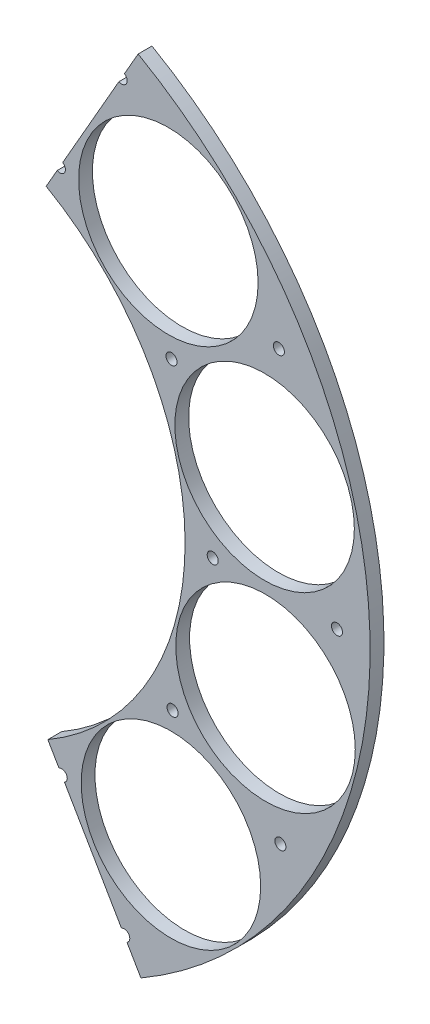
from build123d import *

# Parameters (mm, degrees)
ESQUISSE1_R             = 32.5
BOSS_EXTRU_2_DEPTH      = 5
ESQUISSE2_R             = 2
ENL_V_MAT_EXTRU_1_DEPTH = 5
ENL_V_MAT_EXTRU_2_DEPTH = 10


with BuildPart() as part:
    # Esquisse1 → Boss.-Extru.2 (new body)
    with BuildSketch(Plane.XY):
        with BuildLine():
            Line((-2, 166.988023523), (-2, 99.979998))
            ThreePointArc((-2, 99.979998), (100, 0), (-2, -99.979998))
            Line((-2, -99.979998), (-2, -166.988023523))
            ThreePointArc((-2, -166.988023523), (167, 0), (-2, 166.988023523))
        make_face()
        with Locations((33.922197974, 129.118296475)):
            Circle(ESQUISSE1_R, mode=Mode.SUBTRACT)
        with Locations((93.936633435, 94.858625854)):
            Circle(ESQUISSE1_R, mode=Mode.SUBTRACT)
        with Locations((128.780823828, 35.18166304)):
            Circle(ESQUISSE1_R, mode=Mode.SUBTRACT)
        with Locations((129.118296475, -33.922197974)):
            Circle(ESQUISSE1_R, mode=Mode.SUBTRACT)
        with Locations((94.858625854, -93.936633435)):
            Circle(ESQUISSE1_R, mode=Mode.SUBTRACT)
        with Locations((35.18166304, -128.780823828)):
            Circle(ESQUISSE1_R, mode=Mode.SUBTRACT)
    extrude(amount=BOSS_EXTRU_2_DEPTH)

    # Esquisse2 → Enlèv. mat.-Extru.1 (cut)
    with BuildSketch(Plane(origin=(0, 0, 0), x_dir=(-1, 0, 0), z_dir=(0, 0, -1))):
        with Locations((-77.031940381, 134.503086066)):
            Circle(ESQUISSE2_R)
        with Locations((-54.667828657, 95.453803014)):
            Circle(ESQUISSE2_R)
        with Locations((-77.96711923, -133.963160305)):
            Circle(ESQUISSE2_R)
        with Locations((-55.33150397, -95.070629894)):
            Circle(ESQUISSE2_R)
        with Locations((-134.503086066, -77.031940381)):
            Circle(ESQUISSE2_R)
        with Locations((-95.453803014, -54.667828657)):
            Circle(ESQUISSE2_R)
        with Locations((-154.999059611, 0.53992576)):
            Circle(ESQUISSE2_R)
        with Locations((-109.999332627, 0.38317312)):
            Circle(ESQUISSE2_R)
        with Locations((-133.963160305, 77.96711923)):
            Circle(ESQUISSE2_R)
        with Locations((-95.070629894, 55.33150397)):
            Circle(ESQUISSE2_R)
    extrude(amount=-ENL_V_MAT_EXTRU_1_DEPTH, mode=Mode.SUBTRACT)

    # Esquisse3 → Enlèv. mat.-Extru.2 (cut)
    with BuildSketch(Plane.XY.offset(5)):
        Polygon((0, 0), (77.031940381, 134.503086066), (82.995703507, 144.916228213), (91.624548615, 157.474747761), (25.313830581, 172.484842021), (-36.151543954, 181.613524578), (-51.569744744, -183.237067308), (77.031940381, -179.146608877), (82.995703507, -170.83045621), (84.003283299, -144.334501748), (77.96711923, -133.963160305), align=None)
    extrude(amount=-ENL_V_MAT_EXTRU_2_DEPTH, mode=Mode.SUBTRACT)


solid = part.part
